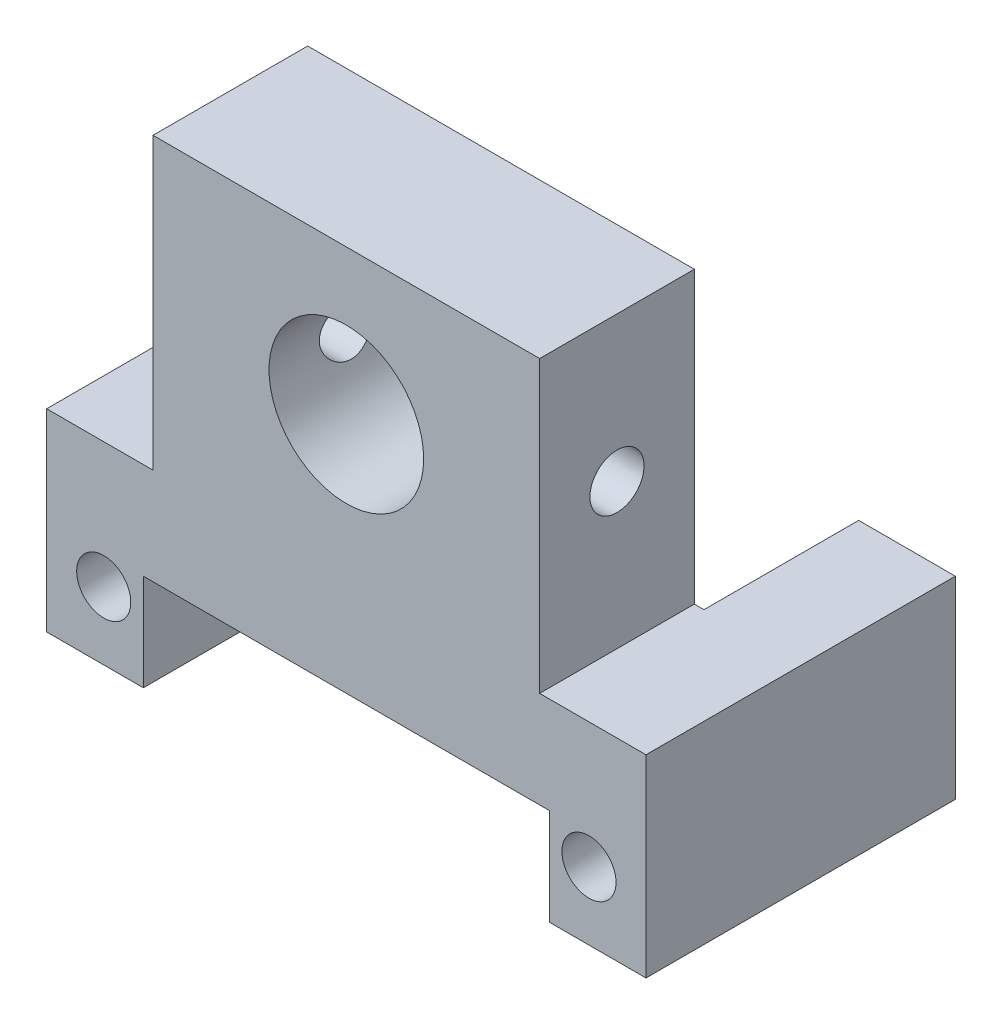
from build123d import *

# Parameters (mm, degrees)
ESQUISSE1_R             = 1.4
BOSS_EXTRU_1_DEPTH      = 16
ESQUISSE2_W             = 20
ESQUISSE2_H             = 16
BOSS_EXTRU_2_DEPTH      = 15
ESQUISSE3_R             = 4
ENL_V_MAT_EXTRU_1_DEPTH = 15
ESQUISSE4_W             = 21
ESQUISSE4_H             = 8
ENL_V_MAT_EXTRU_2_DEPTH = 21
ESQUISSE5_R             = 1.4
ENL_V_MAT_EXTRU_3_DEPTH = 21


with BuildPart() as part:
    # Esquisse1 → Boss.-Extru.1 (new body)
    with BuildSketch(Plane.XY):
        Polygon((15.5, 10), (-15.5, 10), (-15.5, 0), (-10.5, 0), (-10.5, 5), (10.5, 5), (10.5, 0), (15.5, 0), align=None)
        with Locations((12.55, 3.5)):
            Circle(ESQUISSE1_R, mode=Mode.SUBTRACT)
        with Locations((-12.55, 3.5)):
            Circle(ESQUISSE1_R, mode=Mode.SUBTRACT)
    extrude(amount=BOSS_EXTRU_1_DEPTH)

    # Esquisse2 → Boss.-Extru.2 (add)
    with BuildSketch(Plane(origin=(0, 10, 0), x_dir=(1, 0, 0), z_dir=(0, 1, 0))):
        with Locations((0, -8)):
            Rectangle(ESQUISSE2_W, ESQUISSE2_H)
    extrude(amount=BOSS_EXTRU_2_DEPTH)

    # Esquisse3 → Enlèv. mat.-Extru.1 (cut)
    with BuildSketch(Plane.XY.offset(16)):
        with Locations((0, 17.5)):
            Circle(ESQUISSE3_R)
    extrude(amount=-ENL_V_MAT_EXTRU_1_DEPTH, mode=Mode.SUBTRACT)

    # Esquisse4 → Enlèv. mat.-Extru.2 (cut)
    with BuildSketch(Plane.XZ.offset(-5)):
        with Locations((0, 4)):
            Rectangle(ESQUISSE4_W, ESQUISSE4_H)
    extrude(amount=-ENL_V_MAT_EXTRU_2_DEPTH, mode=Mode.SUBTRACT)

    # Esquisse5 → Enlèv. mat.-Extru.3 (cut)
    with BuildSketch(Plane.ZY.offset(10)):
        with Locations((12, 17.5)):
            Circle(ESQUISSE5_R)
    extrude(amount=-ENL_V_MAT_EXTRU_3_DEPTH, mode=Mode.SUBTRACT)


solid = part.part
